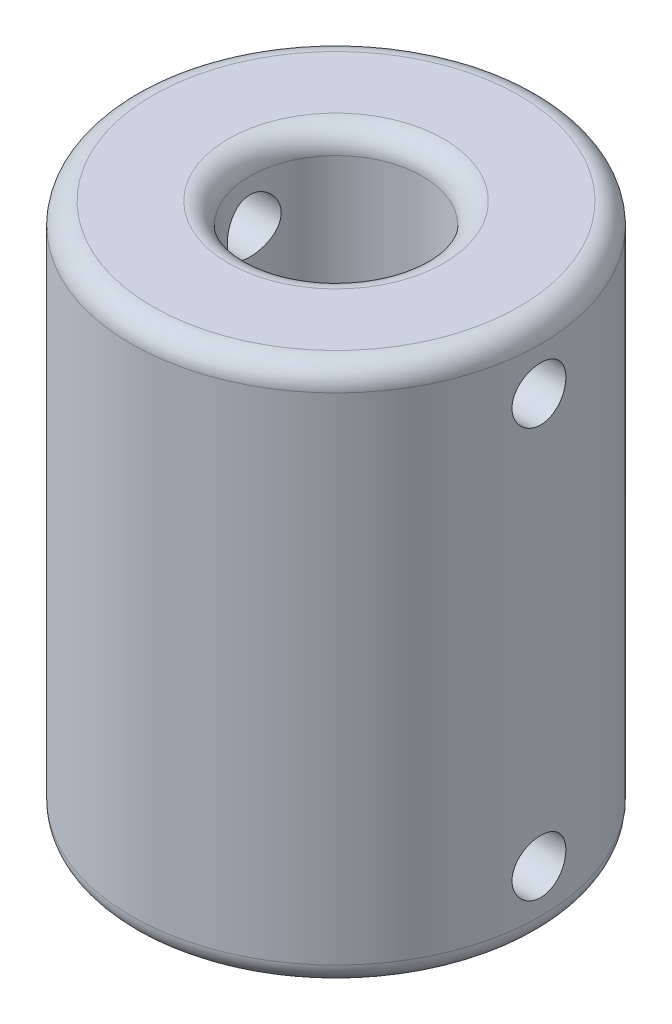
from build123d import *

# Parameters (mm, degrees)
SKETCH1_R                        = 9.5
SKETCH1_R_2                      = 2.5
BOSS_EXTRUDE1_DEPTH              = 25
SKETCH2_R                        = 4
CUT_EXTRUDE1_DEPTH               = 12.5
TAP_DRILL_FOR_M3_TAP1_AT_2_COUNT = 2
TAP_DRILL_FOR_M3_TAP1_AT_2_PITCH = 19
FILLET1_R                        = 1


with BuildPart() as part:
    # Sketch1 → Boss-Extrude1 (new body)
    with BuildSketch(Plane(origin=(0, 0, 0), x_dir=(1, 0, 0), z_dir=(0, 1, 0))):
        Circle(SKETCH1_R)
        Circle(SKETCH1_R_2, mode=Mode.SUBTRACT)
    extrude(amount=BOSS_EXTRUDE1_DEPTH)

    # Sketch2 → Cut-Extrude1 (cut)
    with BuildSketch(Plane(origin=(0, 25, 0), x_dir=(1, 0, 0), z_dir=(0, 1, 0))):
        Circle(SKETCH2_R)
    extrude(amount=-CUT_EXTRUDE1_DEPTH, mode=Mode.SUBTRACT)

    # Sketch7 → Tap Drill for M3 Tap1 (revolve, cut)
    with BuildSketch(Plane.ZX.offset(22)):
        Polygon((0, 0), (0, 9.5), (1.25, 9.5), (1.25, 0.025), (1.275, 0), align=None)
    tap_drill_for_m3_tap1 = revolve(axis=Axis((-6.35, 22, 0), (1, 0, 0)), mode=Mode.SUBTRACT)

    # Tap Drill for M3 Tap1 at 2: Tap Drill for M3 Tap1 ×2
    with Locations(*[(0, -i * TAP_DRILL_FOR_M3_TAP1_AT_2_PITCH, 0) for i in range(1, TAP_DRILL_FOR_M3_TAP1_AT_2_COUNT)]):
        add(tap_drill_for_m3_tap1, mode=Mode.SUBTRACT)

    # Fillet1
    fillet1_edges = [part.edges().sort_by_distance(p)[0] for p in [
        (-4, 25, 0),
        (-9.5, 0, 0),
        (-9.5, 25, 0),
        (-2.5, 0, 0),
    ]]
    fillet(fillet1_edges, radius=FILLET1_R)

    # Mirror3: Tap Drill for M3 Tap1 across plane
    add(tap_drill_for_m3_tap1.mirror(Plane(origin=(0, 0, 0), x_dir=(0, 0, 1), z_dir=(1, 0, 0))), mode=Mode.SUBTRACT)

    # Mirror3 copy 1 sketch → Mirror3 copy 1 (revolve, cut)
    with BuildSketch(Plane.ZX.offset(3)):
        Polygon((0, 0), (0, -9.5), (1.25, -9.5), (1.25, -0.025), (1.275, 0), align=None)
    revolve(axis=Axis((6.35, 3, 0), (1, 0, 0)), mode=Mode.SUBTRACT)


solid = part.part
